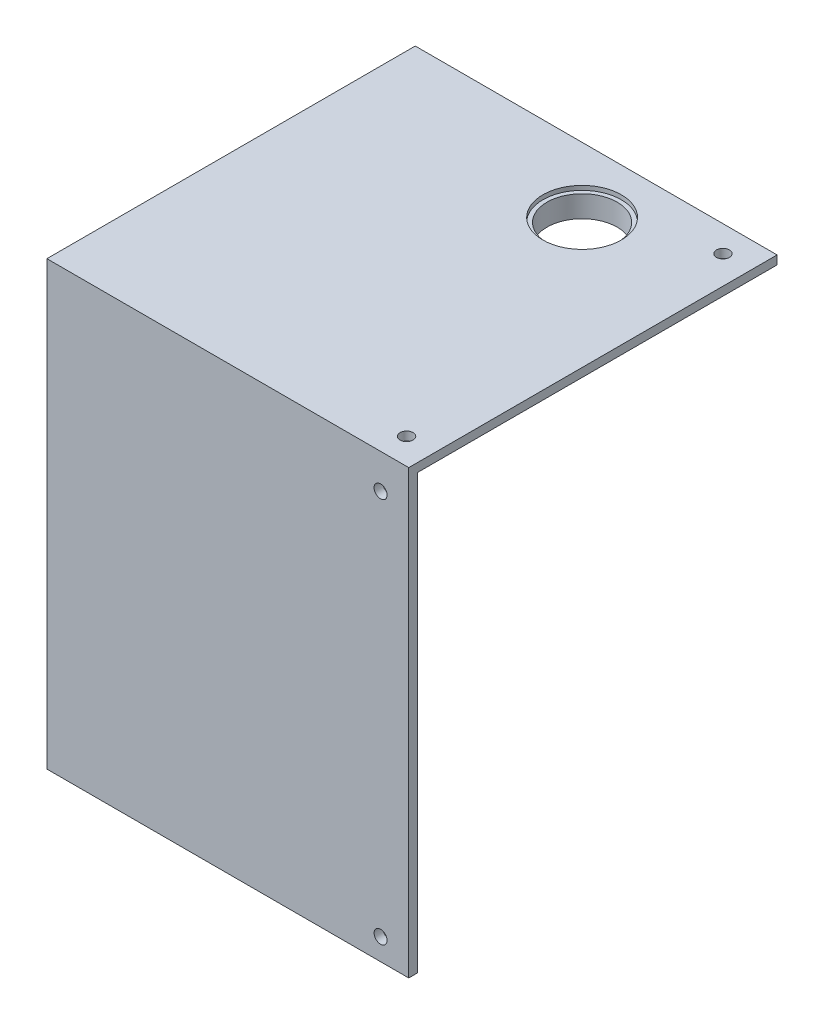
from build123d import *

# Parameters (mm, degrees)
SKETCH1_W               = 83.5
SKETCH1_H               = 85
BOSS_EXTRUDE1_DEPTH     = 2
SKETCH2_W               = 83.5
SKETCH2_H               = 2
BOSS_EXTRUDE2_DEPTH     = 100
SKETCH3_R               = 10.6
BOSS_EXTRUDE3_DEPTH     = 4
CUT_EXTRUDE3_DEPTH      = 117.401514165
CUT_EXTRUDE3_DEPTH_BACK = 117.401514165
SKETCH3_3_R             = 8.1
SKETCH4_R               = 9.05
CUT_EXTRUDE4_DEPTH      = 1
CUT_EXTRUDE5_REACH      = 139.725
SKETCH5_R               = 1.5
CUT_EXTRUDE6_REACH      = 120.124
SKETCH6_R               = 1.5


with BuildPart() as part:
    # Sketch1 → Boss-Extrude1 (new body)
    with BuildSketch(Plane(origin=(0, 0, 0), x_dir=(1, 0, 0), z_dir=(0, 1, 0))):
        Rectangle(SKETCH1_W, SKETCH1_H)
    extrude(amount=BOSS_EXTRUDE1_DEPTH)

    # Sketch2 → Boss-Extrude2 (add)
    with BuildSketch(Plane(origin=(0, 0, 0), x_dir=(-1, 0, 0), z_dir=(0, -1, 0))):
        with Locations((0, -41.5)):
            Rectangle(SKETCH2_W, SKETCH2_H)
    extrude(amount=BOSS_EXTRUDE2_DEPTH)

    # Sketch3 → Boss-Extrude3 (add)
    with BuildSketch(Plane(origin=(0, 0, 0), x_dir=(-1, 0, 0), z_dir=(0, -1, 0))):
        with Locations((-11.75, 27.5)):
            Circle(SKETCH3_R)
    extrude(amount=BOSS_EXTRUDE3_DEPTH)

    # Sketch3_3 → Cut-Extrude3 (cut, two sides: drawn at the far end of the back side and taken through both)
    with BuildSketch(Plane(origin=(0, 0, 0), x_dir=(-1, 0, 0), z_dir=(0, -1, 0)).offset(-CUT_EXTRUDE3_DEPTH_BACK)):
        with Locations((-11.75, 27.5)):
            Circle(SKETCH3_3_R)
    extrude(amount=CUT_EXTRUDE3_DEPTH + CUT_EXTRUDE3_DEPTH_BACK, mode=Mode.SUBTRACT)

    # Sketch4 → Cut-Extrude4 (cut)
    with BuildSketch(Plane(origin=(0, 2, 0), x_dir=(1, 0, 0), z_dir=(0, 1, 0))):
        with Locations((11.75, 27.5)):
            Circle(SKETCH4_R)
    extrude(amount=-CUT_EXTRUDE4_DEPTH, mode=Mode.SUBTRACT)

    # Sketch5 → Cut-Extrude5 (cut, up to next)
    with BuildSketch(Plane.XY.offset(42.5), mode=Mode.PRIVATE) as cut_extrude5_sk1:
        with Locations((35.25, -95)):
            Circle(SKETCH5_R)
    cut_extrude5_tool1 = extrude(cut_extrude5_sk1.sketch, amount=-CUT_EXTRUDE5_REACH, mode=Mode.PRIVATE) & part.part
    # Sketch5 → Cut-Extrude5 (cut, up to next)
    with BuildSketch(Plane.XY.offset(42.5), mode=Mode.PRIVATE) as cut_extrude5_sk2:
        with Locations((35.25, -6)):
            Circle(SKETCH5_R)
    cut_extrude5_tool2 = extrude(cut_extrude5_sk2.sketch, amount=-CUT_EXTRUDE5_REACH, mode=Mode.PRIVATE) & part.part
    add(cut_extrude5_tool1.solids().sort_by_distance((35.25, -95, 42.5))[0], mode=Mode.SUBTRACT)
    add(cut_extrude5_tool2.solids().sort_by_distance((35.25, -6, 42.5))[0], mode=Mode.SUBTRACT)

    # Sketch6 → Cut-Extrude6 (cut, up to next)
    with BuildSketch(Plane(origin=(0, 2, 0), x_dir=(1, 0, 0), z_dir=(0, 1, 0)), mode=Mode.PRIVATE) as cut_extrude6_sk1:
        with Locations((35.25, -36.5)):
            Circle(SKETCH6_R)
    cut_extrude6_tool1 = extrude(cut_extrude6_sk1.sketch, amount=-CUT_EXTRUDE6_REACH, mode=Mode.PRIVATE) & part.part
    # Sketch6 → Cut-Extrude6 (cut, up to next)
    with BuildSketch(Plane(origin=(0, 2, 0), x_dir=(1, 0, 0), z_dir=(0, 1, 0)), mode=Mode.PRIVATE) as cut_extrude6_sk2:
        with Locations((35.25, 36.5)):
            Circle(SKETCH6_R)
    cut_extrude6_tool2 = extrude(cut_extrude6_sk2.sketch, amount=-CUT_EXTRUDE6_REACH, mode=Mode.PRIVATE) & part.part
    add(cut_extrude6_tool1.solids().sort_by_distance((35.25, 2, 36.5))[0], mode=Mode.SUBTRACT)
    add(cut_extrude6_tool2.solids().sort_by_distance((35.25, 2, -36.5))[0], mode=Mode.SUBTRACT)


solid = part.part
